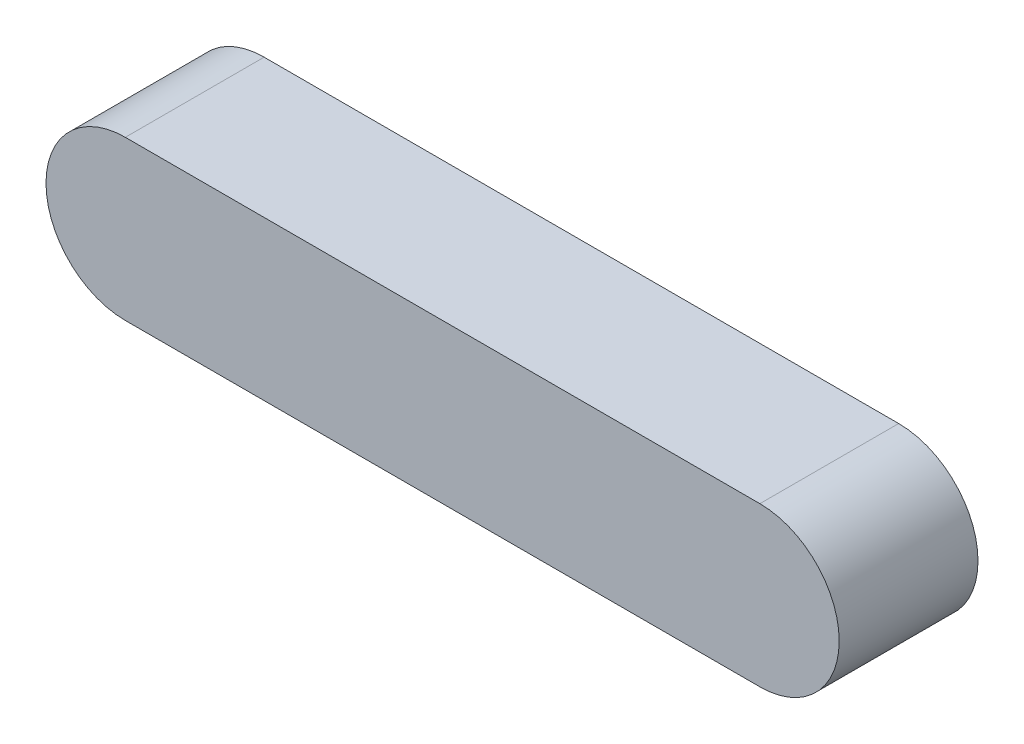
from build123d import *

# Parameters (mm, degrees)
BOSS_EXTRUDE1_DEPTH = 7


with BuildPart() as part:
    # Sketch1 → Boss-Extrude1 (new body)
    with BuildSketch(Plane.XY):
        with BuildLine():
            Line((0, 4), (32, 4))
            ThreePointArc((32, 4), (36, 0), (32, -4))
            Line((32, -4), (0, -4))
            ThreePointArc((0, -4), (-4, 0), (0, 4))
        make_face()
    extrude(amount=BOSS_EXTRUDE1_DEPTH)


solid = part.part
